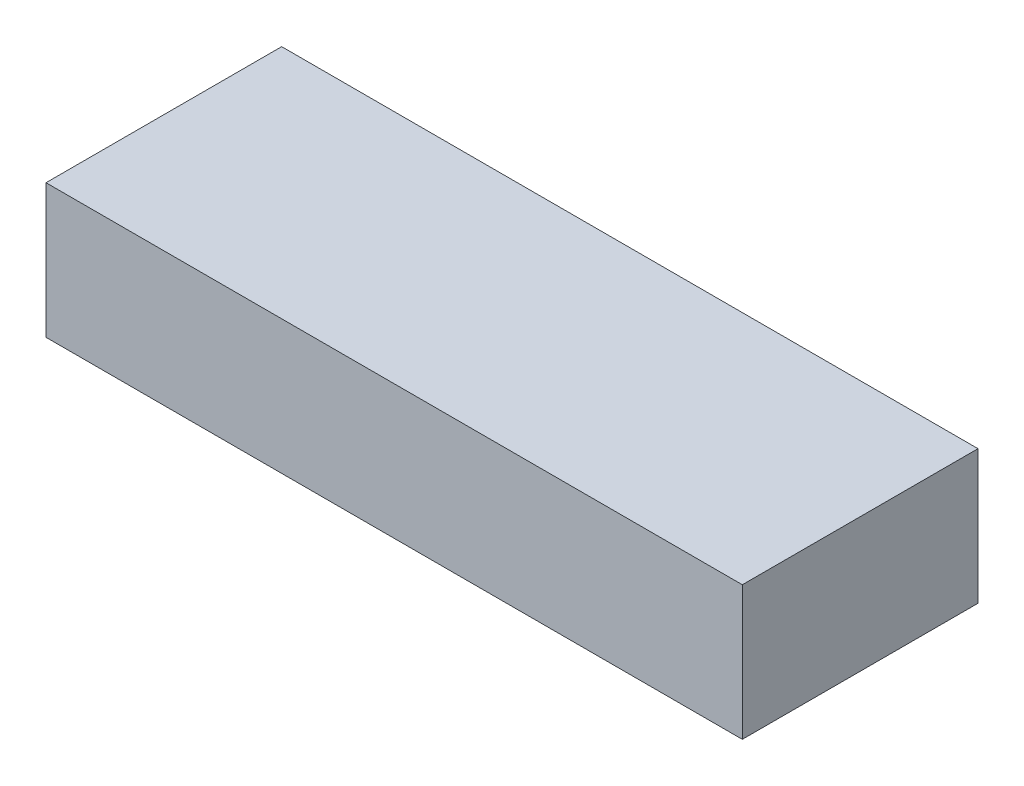
from build123d import *

# Parameters (mm, degrees)
SKETCH1_W           = 130
SKETCH1_H           = 44
BOSS_EXTRUDE1_DEPTH = 25


with BuildPart() as part:
    # Sketch1 → Boss-Extrude1 (new body)
    with BuildSketch(Plane(origin=(0, 0, 0), x_dir=(1, 0, 0), z_dir=(0, 1, 0))):
        with Locations((26.010526316, -0.115789474)):
            Rectangle(SKETCH1_W, SKETCH1_H)
    extrude(amount=BOSS_EXTRUDE1_DEPTH)


solid = part.part
